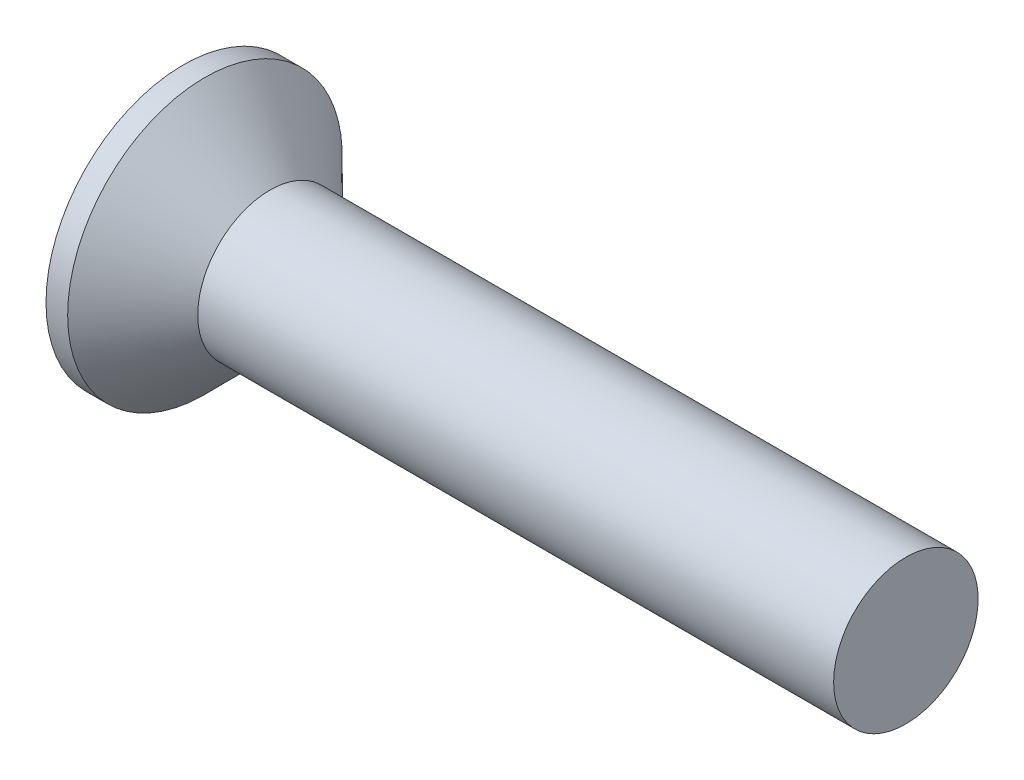
from build123d import *

# Parameters (mm, degrees)
SKETCH3_W         = 0.53
SKETCH3_H         = 2.14
SKETCH4_W         = 0.265
SKETCH4_H         = 0.265
CIRPATTERN1_COUNT = 2
CIRPATTERN1_ANGLE = 90


with BuildPart() as part:
    # BodySke → Base-Revolve (revolve)
    with BuildSketch(Plane.XY):
        Polygon((0, 0), (0, 1.9), (0.3, 1.9), (1.2, 1), (10, 1), (10, 0), align=None)
    revolve(axis=Axis((-6.35, 0, 0), (1, 0, 0)))

    # Sketch3 → Cross section 0
    with BuildSketch(Plane.ZY):
        Rectangle(SKETCH3_W, SKETCH3_H)
    # Sketch4 → Cross section 1
    with BuildSketch(Plane.ZY.offset(-1.54)):
        Rectangle(SKETCH4_W, SKETCH4_H)
    cross = loft(mode=Mode.SUBTRACT)

    # CirPattern1: Cross ×2 about axis
    cirpattern1_axis = Axis((0, 0, 0), (1, 0, 0))
    for i in range(1, CIRPATTERN1_COUNT):
        add(cross.rotate(cirpattern1_axis, i * CIRPATTERN1_ANGLE / (CIRPATTERN1_COUNT - 1)), mode=Mode.SUBTRACT)


solid = part.part
